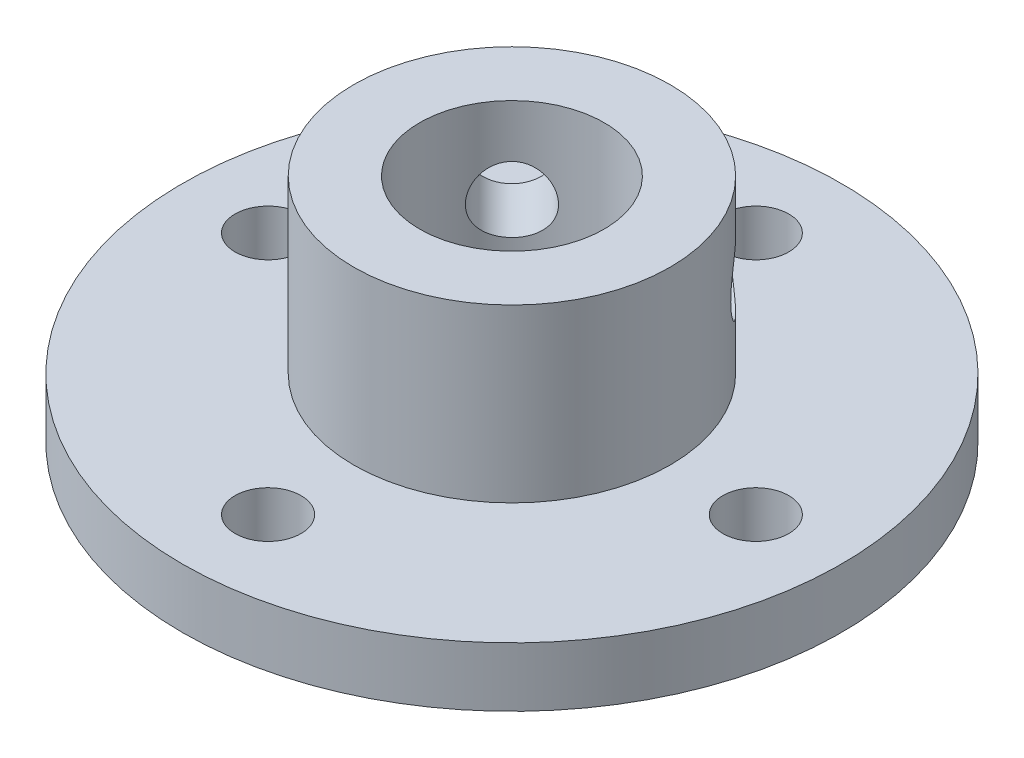
from build123d import *

# Parameters (mm, degrees)
SKETCH1_R           = 25
BOSS_EXTRUDE1_DEPTH = 4.5
SKETCH2_R           = 12
BOSS_EXTRUDE2_DEPTH = 13
SKETCH3_R           = 7
CUT_EXTRUDE1_DEPTH  = 17.5
SKETCH4_R           = 2.5
CUT_EXTRUDE2_DEPTH  = 4.5
SKETCH5_R           = 2.5
CUT_EXTRUDE3_DEPTH  = 25
CIRPATTERN1_COUNT   = 2
CIRPATTERN1_ANGLE   = 90


with BuildPart() as part:
    # Sketch1 → Boss-Extrude1 (new body)
    with BuildSketch(Plane(origin=(0, 0, 0), x_dir=(1, 0, 0), z_dir=(0, 1, 0))):
        Circle(SKETCH1_R)
    extrude(amount=BOSS_EXTRUDE1_DEPTH)

    # Sketch2 → Boss-Extrude2 (add)
    with BuildSketch(Plane(origin=(0, 4.5, 0), x_dir=(1, 0, 0), z_dir=(0, 1, 0))):
        Circle(SKETCH2_R)
    extrude(amount=BOSS_EXTRUDE2_DEPTH)

    # Sketch3 → Cut-Extrude1 (cut)
    with BuildSketch(Plane(origin=(0, 17.5, 0), x_dir=(1, 0, 0), z_dir=(0, 1, 0))):
        Circle(SKETCH3_R)
    extrude(amount=-CUT_EXTRUDE1_DEPTH, mode=Mode.SUBTRACT)

    # Sketch4 → Cut-Extrude2 (cut)
    with BuildSketch(Plane(origin=(0, 4.5, 0), x_dir=(1, 0, 0), z_dir=(0, 1, 0))):
        with Locations((-18.5, 0)):
            Circle(SKETCH4_R)
        with Locations((0, 18.5)):
            Circle(SKETCH4_R)
        with Locations((18.5, 0)):
            Circle(SKETCH4_R)
        with Locations((0, -18.5)):
            Circle(SKETCH4_R)
    extrude(amount=-CUT_EXTRUDE2_DEPTH, mode=Mode.SUBTRACT)

    # Sketch5 → Cut-Extrude3 (cut)
    with BuildSketch(Plane(origin=(0, 0, 0), x_dir=(0.707106781, 0, 0.707106781), z_dir=(-0.707106781, 0, 0.707106781))):
        with Locations((0, 11)):
            Circle(SKETCH5_R)
    cut_extrude3 = extrude(amount=-CUT_EXTRUDE3_DEPTH, mode=Mode.SUBTRACT)

    # CirPattern1: Cut-Extrude3 ×2 about axis
    cirpattern1_axis = Axis((0, 17.5, 0), (0, 1, 0))
    for i in range(1, CIRPATTERN1_COUNT):
        add(cut_extrude3.rotate(cirpattern1_axis, i * CIRPATTERN1_ANGLE / (CIRPATTERN1_COUNT - 1)), mode=Mode.SUBTRACT)


solid = part.part
